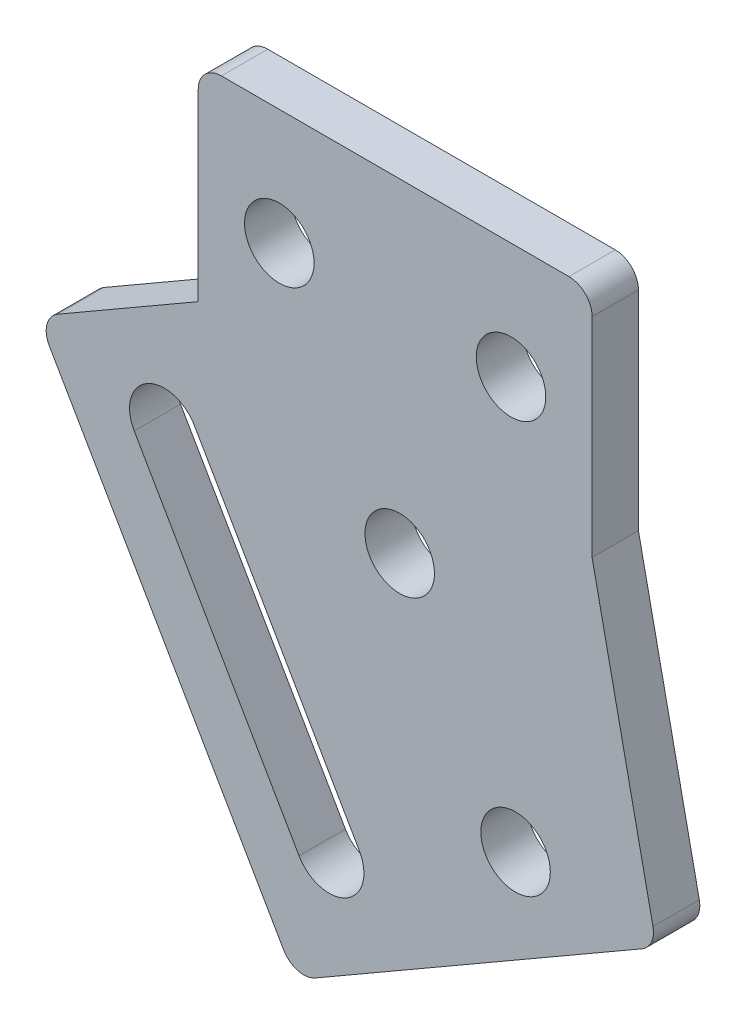
from build123d import *

# Parameters (mm, degrees)
SKETCH_1_R          = 1.5
EXTRUDE_1_DEPTH     = 2
SKETCH_2_W          = 2
SKETCH_2_H          = 22.232050807
EXTRUDE_2_DEPTH     = 8
CUT_EXTRUDE_1_DEPTH = 5
FILLET_1_R          = 1


with BuildPart() as part:
    # 草图1 → 凸台-拉伸1 (new body)
    with BuildSketch(Plane.XY):
        Polygon((-17, 0), (0, 0), (0, -10), (2.776279442, -23.191342951), (-5.883974596, -28.191342951), (-17, -8.937822174), align=None)
        with Locations((-3.303847577, -22.660254038)):
            Circle(SKETCH_1_R, mode=Mode.SUBTRACT)
        with Locations((-13.5, -5)):
            Circle(SKETCH_1_R, mode=Mode.SUBTRACT)
        with Locations((-8.303847577, -14)):
            Circle(SKETCH_1_R, mode=Mode.SUBTRACT)
        with Locations((-3.5, -5)):
            Circle(SKETCH_1_R, mode=Mode.SUBTRACT)
    extrude(amount=EXTRUDE_1_DEPTH)

    # 草图2 → 凸台-拉伸2 (add)
    with BuildSketch(Plane(origin=(-16.620190528, -9.595671476, 0), x_dir=(0, 0, 1), z_dir=(-0.866025404, -0.5, 0))):
        with Locations((1, -10.356406461)):
            Rectangle(SKETCH_2_W, SKETCH_2_H)
    extrude(amount=EXTRUDE_2_DEPTH)

    # 草图3 → 切除-拉伸1 (cut)
    with BuildSketch(Plane(origin=(0, 0, 0), x_dir=(-1, 0, 0), z_dir=(0, 0, -1))):
        with BuildLine():
            Line((10.049038106, -25.977241336), (17.165063509, -13.651923789))
            ThreePointArc((17.165063509, -13.651923789), (19.214101615, -13.102885683), (19.763139721, -15.151923789))
            Line((19.763139721, -15.151923789), (12.647114317, -27.477241336))
            ThreePointArc((12.647114317, -27.477241336), (10.598076211, -28.026279442), (10.049038106, -25.977241336))
        make_face()
    extrude(amount=-CUT_EXTRUDE_1_DEPTH, mode=Mode.SUBTRACT)

    # 圆角1
    fillet_1_edges = [part.edges().sort_by_distance(p)[0] for p in [
        (2.776279442, -23.191342951, 1),
        (-17, 0, 1),
        (0, 0, 1),
        (-23.92820323, -12.937822174, 1),
        (-12.812177826, -32.191342951, 1),
    ]]
    fillet(fillet_1_edges, radius=FILLET_1_R)


solid = part.part
